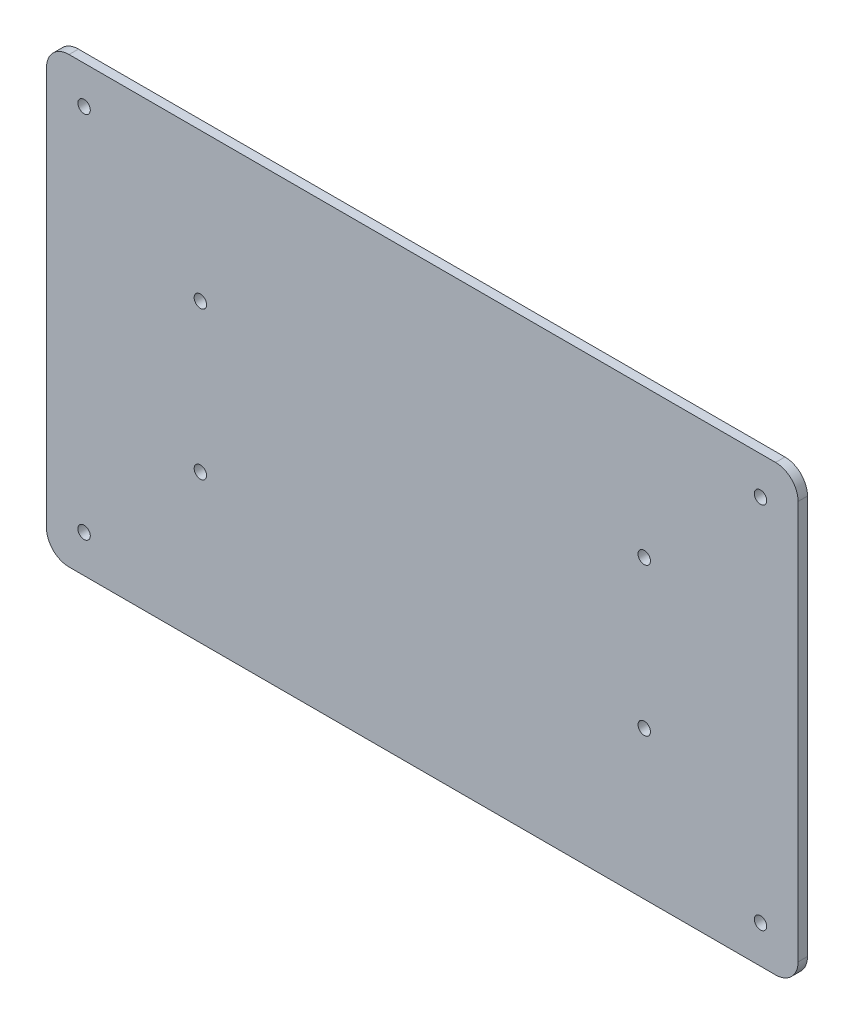
from build123d import *

# Parameters (mm, degrees)
SKETCH1_R           = 2.1
SKETCH1_R_2         = 2.0999958
BOSS_EXTRUDE1_DEPTH = 3.175


with BuildPart() as part:
    # Sketch1 → Boss-Extrude1 (new body)
    with BuildSketch(Plane.XY):
        with BuildLine():
            Line((-119.38, 75), (119.38, 75))
            ThreePointArc((119.38, 75), (124.768153673, 72.768153673), (127, 67.38))
            Line((127, 67.38), (127, -67.38))
            ThreePointArc((127, -67.38), (124.768153673, -72.768153673), (119.38, -75))
            Line((119.38, -75), (-119.38, -75))
            ThreePointArc((-119.38, -75), (-124.768153673, -72.768153673), (-127, -67.38))
            Line((-127, -67.38), (-127, 67.38))
            ThreePointArc((-127, 67.38), (-124.768153673, 72.768153673), (-119.38, 75))
        make_face()
        with Locations((-75, 25)):
            Circle(SKETCH1_R, mode=Mode.SUBTRACT)
        with Locations((-75, -25)):
            Circle(SKETCH1_R, mode=Mode.SUBTRACT)
        with Locations((75, -25)):
            Circle(SKETCH1_R, mode=Mode.SUBTRACT)
        with Locations((75, 25)):
            Circle(SKETCH1_R, mode=Mode.SUBTRACT)
        with Locations((-114.3, 62.3)):
            Circle(SKETCH1_R_2, mode=Mode.SUBTRACT)
        with Locations((114.3, 62.3)):
            Circle(SKETCH1_R, mode=Mode.SUBTRACT)
        with Locations((-114.3, -62.3)):
            Circle(SKETCH1_R, mode=Mode.SUBTRACT)
        with Locations((114.3, -62.3)):
            Circle(SKETCH1_R, mode=Mode.SUBTRACT)
    extrude(amount=BOSS_EXTRUDE1_DEPTH)


solid = part.part
